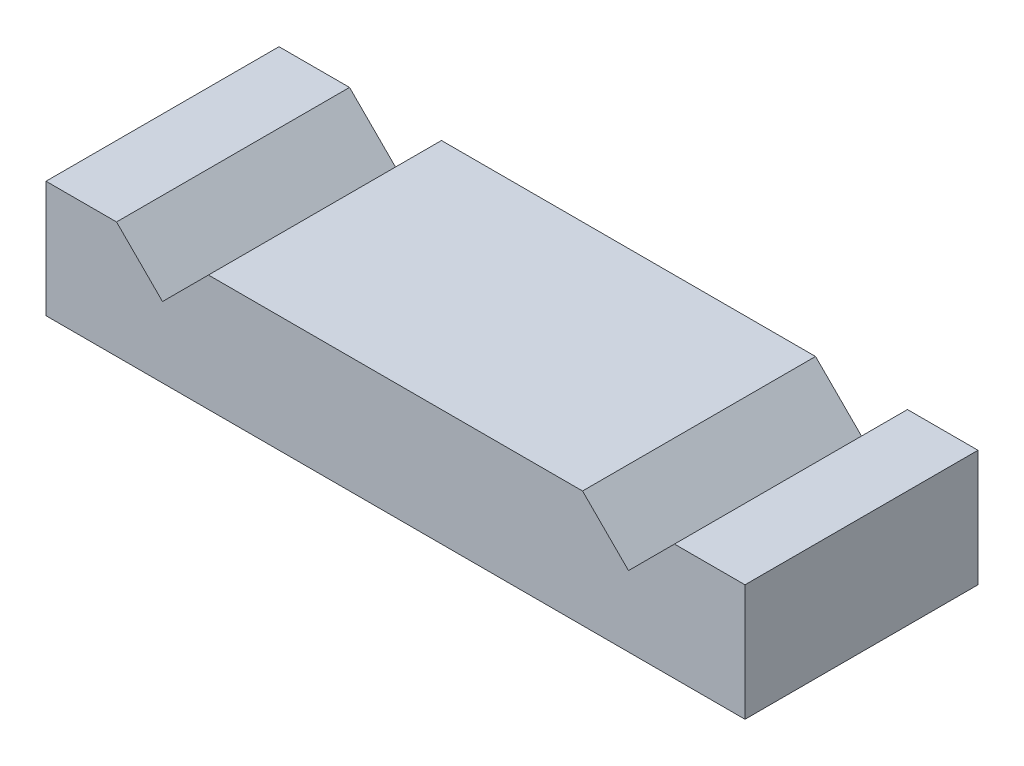
from build123d import *

# Parameters (mm, degrees)
SKETCH1_W           = 60
SKETCH1_H           = 20
BOSS_EXTRUDE1_DEPTH = 10
CUT_EXTRUDE1_DEPTH  = 65.031242374


with BuildPart() as part:
    # Sketch1 → Boss-Extrude1 (new body)
    with BuildSketch(Plane(origin=(0, 0, 0), x_dir=(1, 0, 0), z_dir=(0, 1, 0))):
        with Locations((30, 10)):
            Rectangle(SKETCH1_W, SKETCH1_H)
    extrude(amount=BOSS_EXTRUDE1_DEPTH)

    # Sketch2 → Cut-Extrude1 (cut, through all)
    with BuildSketch(Plane.XY):
        Polygon((13.94522636, 10), (6.05477364, 10), (10, 6.05477364), align=None)
        Polygon((46.05477364, 10), (50, 6.05477364), (53.94522636, 10), align=None)
    extrude(amount=-CUT_EXTRUDE1_DEPTH, mode=Mode.SUBTRACT)


solid = part.part
